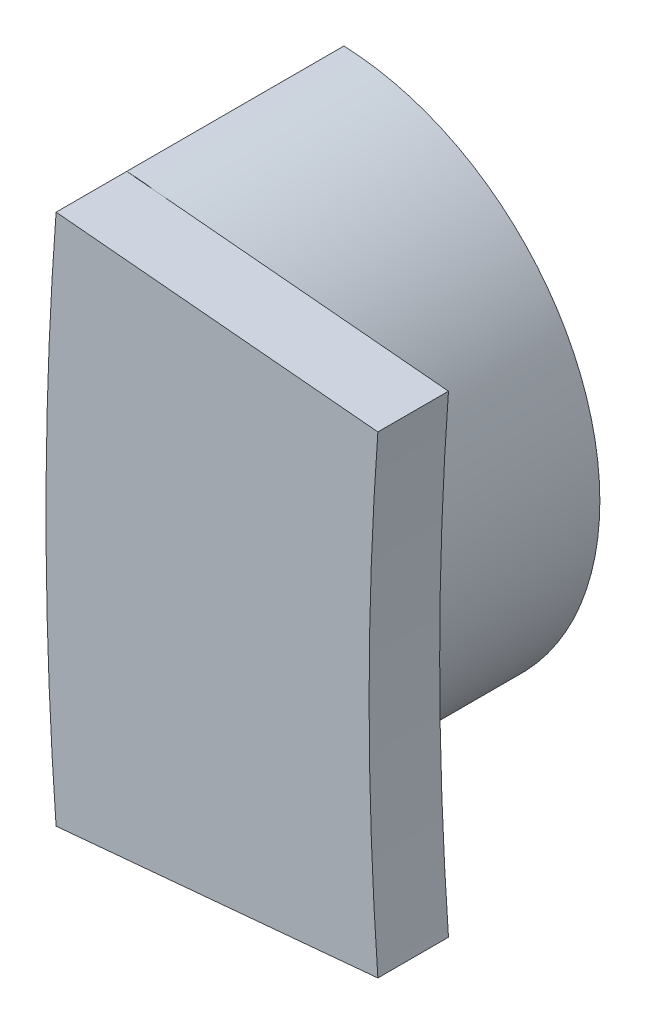
from build123d import *

# Parameters (mm, degrees)
BOSS_EXTRUDE1_DEPTH = 5.08
BOSS_EXTRUDE2_DEPTH = 1.651
SKETCH4_R           = 1.03378
CUT_EXTRUDE1_DEPTH  = 3.175


with BuildPart() as part:
    # Sketch2 → Boss-Extrude1 (new body)
    with BuildSketch(Plane.XY):
        with BuildLine():
            ThreePointArc((-81.80598839, 6.218522937), (-75.819, 0), (-81.80598839, -6.218522937))
            ThreePointArc((-81.80598839, -6.218522937), (-82.042, 0), (-81.80598839, 6.218522937))
        make_face()
    extrude(amount=BOSS_EXTRUDE1_DEPTH)

    # Sketch3 → Boss-Extrude2 (add)
    with BuildSketch(Plane.XY.offset(5.08)):
        with BuildLine():
            Line((-81.80598839, 6.218522937), (-74.279907283, 5.53037832))
            ThreePointArc((-74.279907283, 5.53037832), (-74.4855, 0), (-74.279907283, -5.53037832))
            Line((-74.279907283, -5.53037832), (-81.80598839, -6.218522937))
            ThreePointArc((-81.80598839, -6.218522937), (-82.042, 0), (-81.80598839, 6.218522937))
        make_face()
    extrude(amount=BOSS_EXTRUDE2_DEPTH)

    # Sketch4 → Cut-Extrude1 (cut)
    with BuildSketch(Plane.ZY.offset(82.042)):
        with Locations((3.683, 0)):
            Circle(SKETCH4_R)
    extrude(amount=-CUT_EXTRUDE1_DEPTH, mode=Mode.SUBTRACT)


solid = part.part
